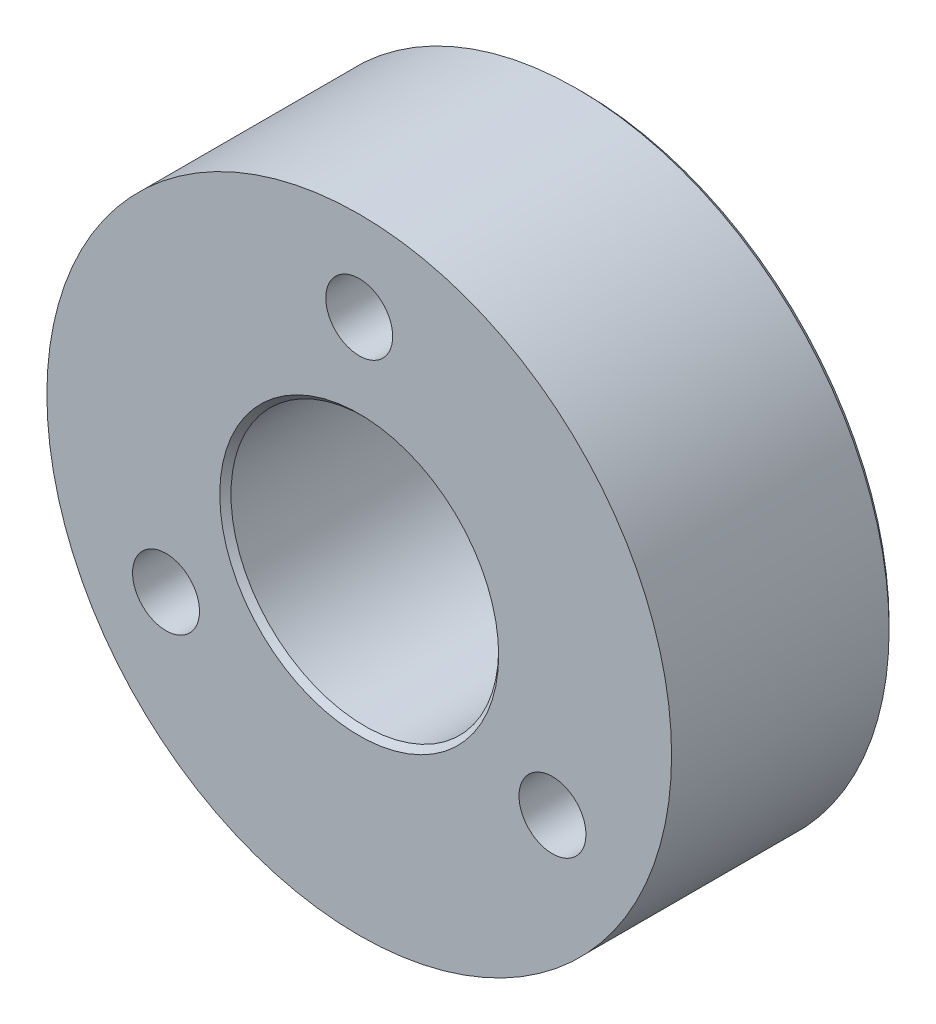
from build123d import *

# Parameters (mm, degrees)
SKETCH2_R           = 14
SKETCH2_R_2         = 6
SKETCH2_R_3         = 1.5
BOSS_EXTRUDE1_DEPTH = 10
CHAMFER1_SIZE       = 0.25


with BuildPart() as part:
    # Sketch2 → Boss-Extrude1 (new body)
    with BuildSketch(Plane.XY):
        Circle(SKETCH2_R)
        Circle(SKETCH2_R_2, mode=Mode.SUBTRACT)
        with Locations((0, 10)):
            Circle(SKETCH2_R_3, mode=Mode.SUBTRACT)
        with Locations((8.660254038, -5)):
            Circle(SKETCH2_R_3, mode=Mode.SUBTRACT)
        with Locations((-8.660254038, -5)):
            Circle(SKETCH2_R_3, mode=Mode.SUBTRACT)
    extrude(amount=BOSS_EXTRUDE1_DEPTH)

    # Chamfer1
    chamfer1_edges = [part.edges().sort_by_distance(p)[0] for p in [
        (7.160254038, -5, 0),
        (-10.160254038, -5, 0),
        (-14, 0, 0),
        (-6, 0, 0),
        (-6, 0, 10),
        (-1.5, 10, 0),
    ]]
    chamfer(chamfer1_edges, length=CHAMFER1_SIZE)


solid = part.part
